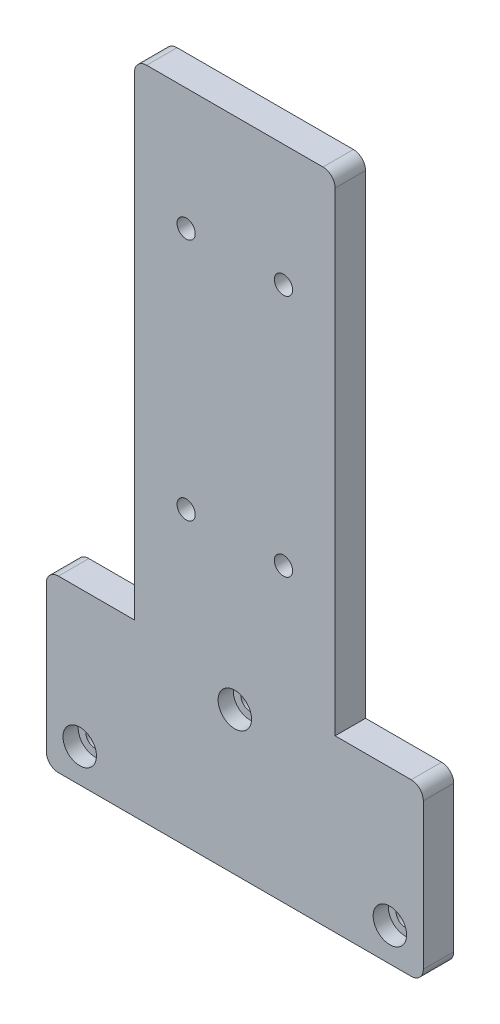
from build123d import *

# Parameters (mm, degrees)
BOSS_EXTRUDE1_DEPTH = 5
HOLE1_D             = 3
HOLE1_CBORE_D       = 5.5
HOLE1_CBORE_DEPTH   = 2.5
HOLE2_D             = 3
HOLE2_CBORE_D       = 5.5
HOLE2_CBORE_DEPTH   = 2.5
FILLET1_R           = 2


with BuildPart() as part:
    # Sketch2 → Boss-Extrude1 (new body)
    with BuildSketch(Plane.XY):
        Polygon((-31, 0), (-31, 28), (-16.5, 28), (-16.5, 108), (16.5, 108), (16.5, 28), (31, 28), (31, 0), align=None)
    extrude(amount=BOSS_EXTRUDE1_DEPTH)

    # Hole1 (through all)
    with Locations(Plane.XY.offset(5)):
        with Locations((-25.5, 5.5), (25.5, 5.5), (0, 23.5)):
            CounterBoreHole(HOLE1_D / 2, HOLE1_CBORE_D / 2, HOLE1_CBORE_DEPTH)

    # Hole2 (through all)
    with Locations(Plane(origin=(0, 0, 0), x_dir=(1, 0, 0), z_dir=(0, 0, -1))):
        with Locations((8, -48), (-8, -48), (-8, -88), (8, -88)):
            CounterBoreHole(HOLE2_D / 2, HOLE2_CBORE_D / 2, HOLE2_CBORE_DEPTH)

    # Fillet1
    fillet1_edges = [part.edges().sort_by_distance(p)[0] for p in [
        (-31, 0, 2.5),
        (-31, 28, 2.5),
        (-16.5, 108, 2.5),
        (16.5, 108, 2.5),
        (31, 28, 2.5),
        (31, 0, 2.5),
    ]]
    fillet(fillet1_edges, radius=FILLET1_R)


solid = part.part
